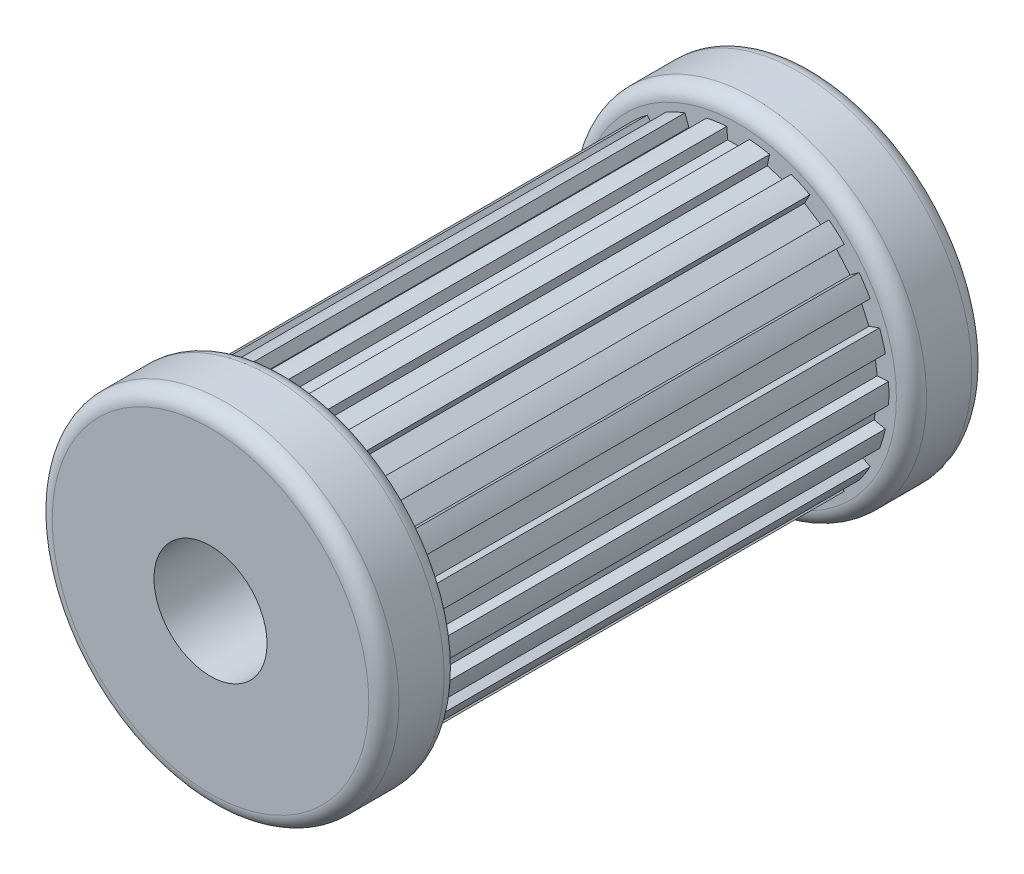
from build123d import *

# Parameters (mm, degrees)
SKETCH1_R           = 20
BOSS_EXTRUDE1_DEPTH = 70
CUT_EXTRUDE1_DEPTH  = 71
CIRPATTERN1_COUNT   = 22
SKETCH3_R           = 23
BOSS_EXTRUDE2_DEPTH = 10
SKETCH5_R           = 23
BOSS_EXTRUDE3_DEPTH = 10
SKETCH6_R           = 7.5
CUT_EXTRUDE2_DEPTH  = 81
FILLET1_R           = 2


with BuildPart() as part:
    # Sketch1 → Boss-Extrude1 (new body)
    with BuildSketch(Plane.XY):
        Circle(SKETCH1_R)
    extrude(amount=BOSS_EXTRUDE1_DEPTH)

    # Sketch2 → Cut-Extrude1 (cut, through all)
    with BuildSketch(Plane.XY.offset(70)):
        with BuildLine():
            Line((-1.3875, 18.447895375), (1.3875, 18.447895375))
            Line((1.3875, 18.447895375), (1.5, 19.943670675))
            ThreePointArc((1.5, 19.943670675), (0, 20), (-1.5, 19.943670675))
            Line((-1.5, 19.943670675), (-1.3875, 18.447895375))
        make_face()
    cut_extrude1 = extrude(amount=-CUT_EXTRUDE1_DEPTH, mode=Mode.SUBTRACT)

    # CirPattern1: Cut-Extrude1 ×22 about axis
    cirpattern1_axis = Axis((0, 0, 0), (0, 0, 1))
    for i in range(1, CIRPATTERN1_COUNT):
        add(cut_extrude1.rotate(cirpattern1_axis, i * 360 / CIRPATTERN1_COUNT), mode=Mode.SUBTRACT)

    # Sketch3 → Boss-Extrude2 (add)
    with BuildSketch(Plane.XY.offset(70)):
        Circle(SKETCH3_R)
    extrude(amount=-BOSS_EXTRUDE2_DEPTH)

    # Sketch5 → Boss-Extrude3 (add)
    with BuildSketch(Plane(origin=(0, 0, 0), x_dir=(-1, 0, 0), z_dir=(0, 0, -1))):
        Circle(SKETCH5_R)
    extrude(amount=BOSS_EXTRUDE3_DEPTH)

    # Sketch6 → Cut-Extrude2 (cut, through all)
    with BuildSketch(Plane.XY.offset(70)):
        Circle(SKETCH6_R)
    extrude(amount=-CUT_EXTRUDE2_DEPTH, mode=Mode.SUBTRACT)

    # Fillet1
    fillet1_edges = [part.edges().sort_by_distance(p)[0] for p in [
        (-23, 0, 70),
        (-23, 0, 60),
        (23, 0, 0),
        (23, 0, -10),
    ]]
    fillet(fillet1_edges, radius=FILLET1_R)


solid = part.part
